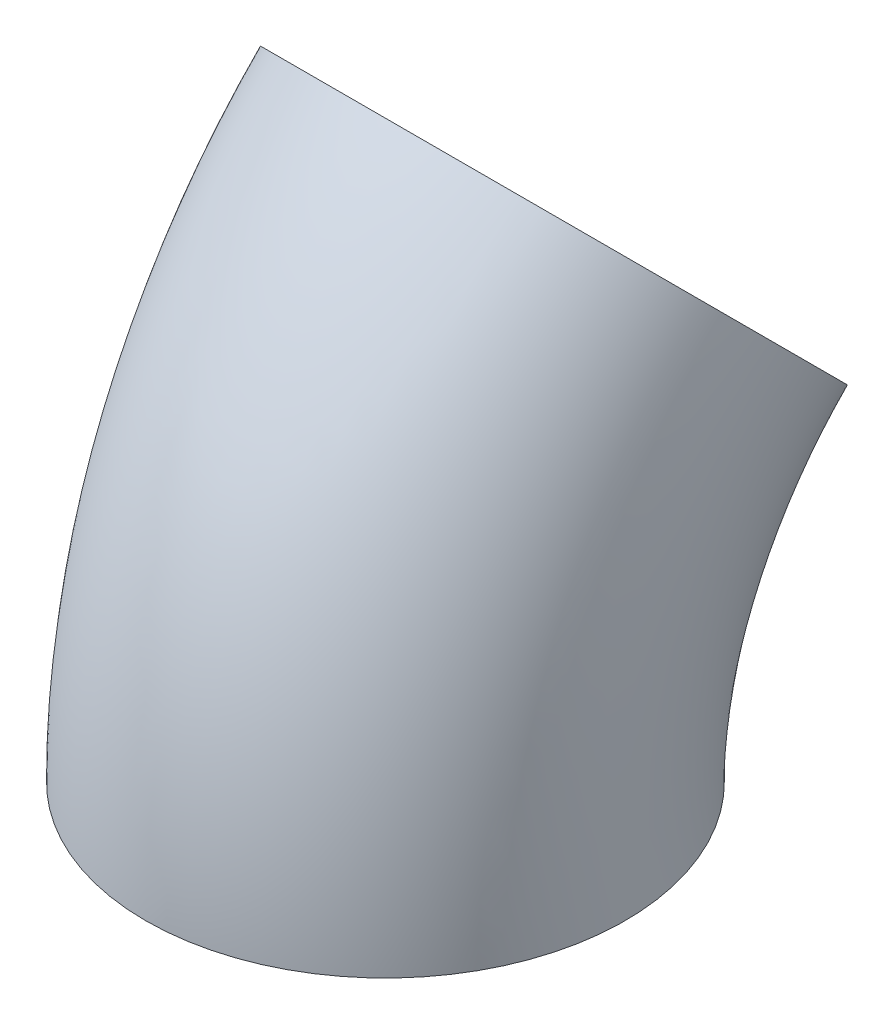
from build123d import *

# Parameters (mm, degrees)
SKIZZE2_R   = 25
SKIZZE2_R_2 = 20


with BuildPart() as part:
    # Austragung1: sweep along a path in Skizze1
    with BuildLine(Plane(origin=(0, 0, 0), x_dir=(0, 0, -1), z_dir=(1, 0, 0))) as austragung1_path:
        ThreePointArc((17.573593129, 42.426406871), (4.567228049, 22.961005942), (0, 0))
    # Skizze2 → Austragung1 (sweep)
    with BuildSketch(Plane(origin=(0, 0, 0), x_dir=(1, 0, 0), z_dir=(0, 1, 0))):
        Circle(SKIZZE2_R)
        Circle(SKIZZE2_R_2, mode=Mode.SUBTRACT)
    sweep(path=austragung1_path.line)


solid = part.part
